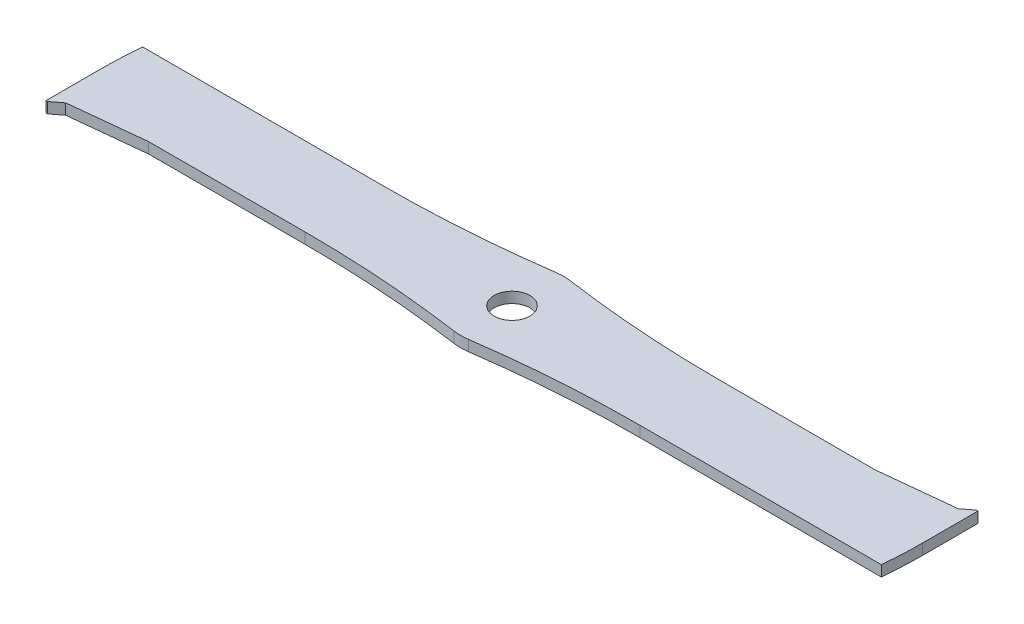
from build123d import *

# Parameters (mm, degrees)
SKETCH1_W           = 330.2
SKETCH1_H           = 31.75
SKETCH1_R           = 7.19455
BOSS_EXTRUDE1_DEPTH = 2.159
SKETCH2_R           = 20.6375
SKETCH2_R_2         = 7.19455
BOSS_EXTRUDE2_DEPTH = 4.318
FILLET1_R           = 457.2
BOSS_EXTRUDE3_DEPTH = 4.318
CUT_EXTRUDE2_DEPTH  = 5.318


with BuildPart() as part:
    # Sketch1 → Boss-Extrude1 (new body, symmetric)
    with BuildSketch(Plane(origin=(0, 0, 0), x_dir=(1, 0, 0), z_dir=(0, 1, 0))):
        Rectangle(SKETCH1_W, SKETCH1_H)
        Circle(SKETCH1_R, mode=Mode.SUBTRACT)
    extrude(amount=BOSS_EXTRUDE1_DEPTH, both=True)

    # Sketch2 → Boss-Extrude2 (add)
    with BuildSketch(Plane(origin=(0, 2.159, 0), x_dir=(1, 0, 0), z_dir=(0, 1, 0))):
        Circle(SKETCH2_R)
        Circle(SKETCH2_R_2, mode=Mode.SUBTRACT)
    extrude(amount=-BOSS_EXTRUDE2_DEPTH)

    # Fillet1
    fillet1_edges = [part.edges().sort_by_distance(p)[0] for p in [
        (13.186765382, 0, 15.875),
        (-13.186765382, 0, 15.875),
        (13.186765382, 0, -15.875),
        (-13.186765382, 0, -15.875),
    ]]
    fillet(fillet1_edges, radius=FILLET1_R)

    # Sketch5 → Boss-Extrude3 (add)
    with BuildSketch(Plane.XZ.offset(2.159)):
        Polygon((-165.1, 15.875), (-165.1, 22.225), (-164.465, 22.225), (-160.3375, 19.05), (-130.175, 15.875), align=None)
        Polygon((165.1, -15.875), (165.1, -22.225), (164.465, -22.225), (160.3375, -19.05), (130.175, -15.875), align=None)
    extrude(amount=-BOSS_EXTRUDE3_DEPTH)

    # Sketch7 → Cut-Extrude2 (cut, through all)
    with BuildSketch(Plane.XZ.offset(2.159)):
        with BuildLine():
            Line((164.335006542, 15.875), (165.1, 15.875))
            Line((165.1, 15.875), (165.1, 0))
            ThreePointArc((165.1, 0), (164.908640738, 7.94671064), (164.335006542, 15.875))
        make_face()
        with BuildLine():
            Line((-164.335006542, -15.875), (-165.1, -15.875))
            Line((-165.1, -15.875), (-165.1, 0))
            ThreePointArc((-165.1, 0), (-164.908640738, -7.94671064), (-164.335006542, -15.875))
        make_face()
    extrude(amount=-CUT_EXTRUDE2_DEPTH, mode=Mode.SUBTRACT)


solid = part.part
